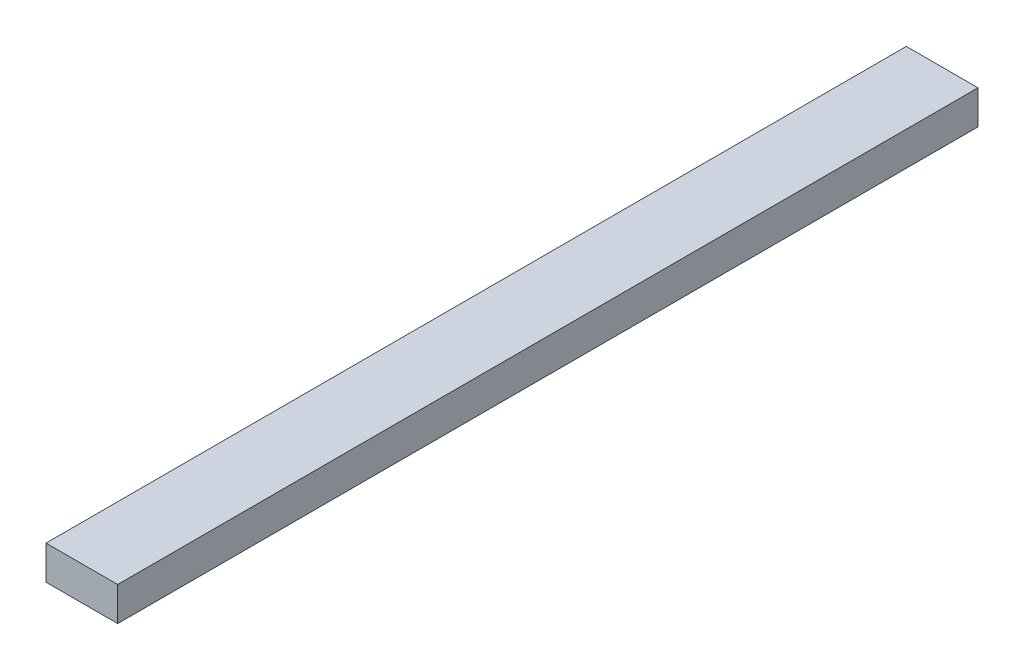
from build123d import *

# Parameters (mm, degrees)
SKETCH1_W           = 6.35
SKETCH1_H           = 3
BOSS_EXTRUDE1_DEPTH = 76.2


with BuildPart() as part:
    # Sketch1 → Boss-Extrude1 (new body)
    with BuildSketch(Plane.XY):
        Rectangle(SKETCH1_W, SKETCH1_H)
    extrude(amount=BOSS_EXTRUDE1_DEPTH)


solid = part.part
